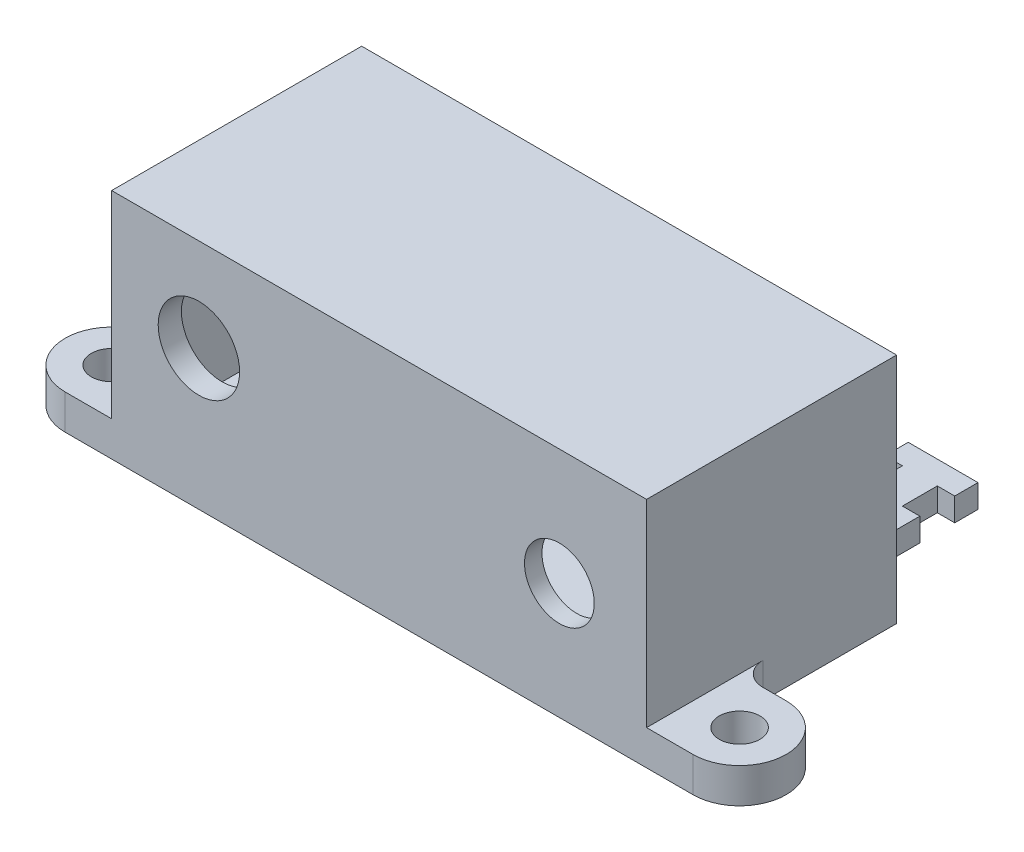
from build123d import *

# Parameters (mm, degrees)
SKETCH_1_W      = 46
SKETCH_1_H      = 20
SKETCH_1_R      = 3.5
SKETCH_1_R_2    = 3
EXTRUDE_1_DEPTH = 1.5
SKETCH_2_R      = 5
SKETCH_2_R_2    = 3.5
EXTRUDE_2_DEPTH = 0.5
SKETCH_3_W      = 46
SKETCH_3_H      = 20
SKETCH_3_W_2    = 43.5
SKETCH_3_H_2    = 16.5
EXTRUDE_3_DEPTH = 20
SKETCH_4_R      = 1.75
EXTRUDE_4_DEPTH = 3
FILLET_1_R      = 2
EXTRUDE_5_DEPTH = 2
FILLET_2_R      = 2


with BuildPart() as part:
    # Эскиз1 → Бобышка-Вытянуть1 (new body)
    with BuildSketch(Plane.XY):
        with Locations((23, 10)):
            Rectangle(SKETCH_1_W, SKETCH_1_H)
        with Locations((7.5, 12)):
            Circle(SKETCH_1_R, mode=Mode.SUBTRACT)
        with Locations((38.5, 10)):
            Circle(SKETCH_1_R_2, mode=Mode.SUBTRACT)
    extrude(amount=EXTRUDE_1_DEPTH)

    # Эскиз2 → Бобышка-Вытянуть2 (add)
    with BuildSketch(Plane(origin=(0, 0, 0), x_dir=(-1, 0, 0), z_dir=(0, 0, -1))):
        with Locations((-7.5, 12)):
            Circle(SKETCH_2_R)
        with Locations((-7.5, 12)):
            Circle(SKETCH_2_R_2, mode=Mode.SUBTRACT)
    extrude(amount=EXTRUDE_2_DEPTH)

    # Эскиз3 → Бобышка-Вытянуть3 (add)
    with BuildSketch(Plane(origin=(0, 0, 0), x_dir=(-1, 0, 0), z_dir=(0, 0, -1))):
        with Locations((-23, 10)):
            Rectangle(SKETCH_3_W, SKETCH_3_H)
        with Locations((-22.75, 10.25)):
            Rectangle(SKETCH_3_W_2, SKETCH_3_H_2, mode=Mode.SUBTRACT)
    extrude(amount=EXTRUDE_3_DEPTH)

    # Эскиз4 → Бобышка-Вытянуть4 (add)
    with BuildSketch(Plane.XZ):
        with BuildLine():
            Line((0, 1.5), (-4, 1.5))
            ThreePointArc((-4, 1.5), (-8, -2.5), (-4, -6.5))
            Line((-4, -6.5), (0, -6.5))
            Line((0, -6.5), (0, 1.5))
        make_face()
        with Locations((-4, -2.5)):
            Circle(SKETCH_4_R, mode=Mode.SUBTRACT)
        with BuildLine():
            Line((50, 1.5), (46, 1.5))
            Line((46, 1.5), (46, -6.5))
            Line((46, -6.5), (50, -6.5))
            ThreePointArc((50, -6.5), (54, -2.5), (50, 1.5))
        make_face()
        with Locations((50, -2.5)):
            Circle(SKETCH_4_R, mode=Mode.SUBTRACT)
    extrude(amount=-EXTRUDE_4_DEPTH)

    # Скругление1
    fillet_1_edges = [part.edges().sort_by_distance(p)[0] for p in [
        (0, 1.5, -6.5),
        (46, 1.5, -6.5),
    ]]
    fillet(fillet_1_edges, radius=FILLET_1_R)

    # Эскиз5 → Бобышка-Вытянуть5 (add)
    with BuildSketch(Plane.XZ):
        Polygon((41, -20), (35, -20), (35, -27), (36.5, -27), (36.5, -30), (35, -30), (35, -32), (41, -32), (41, -30), (39.5, -30), (39.5, -27), (41, -27), align=None)
        Polygon((11, -20), (5, -20), (5, -27), (6.5, -27), (6.5, -30), (5, -30), (5, -32), (11, -32), (11, -30), (9.5, -30), (9.5, -27), (11, -27), align=None)
    extrude(amount=-EXTRUDE_5_DEPTH)

    # Скругление2
    fillet_2_edges = [part.edges().sort_by_distance(p)[0] for p in [
        (41, 1, -20),
        (35, 1, -20),
        (11, 1, -20),
        (5, 1, -20),
    ]]
    fillet(fillet_2_edges, radius=FILLET_2_R)


solid = part.part
